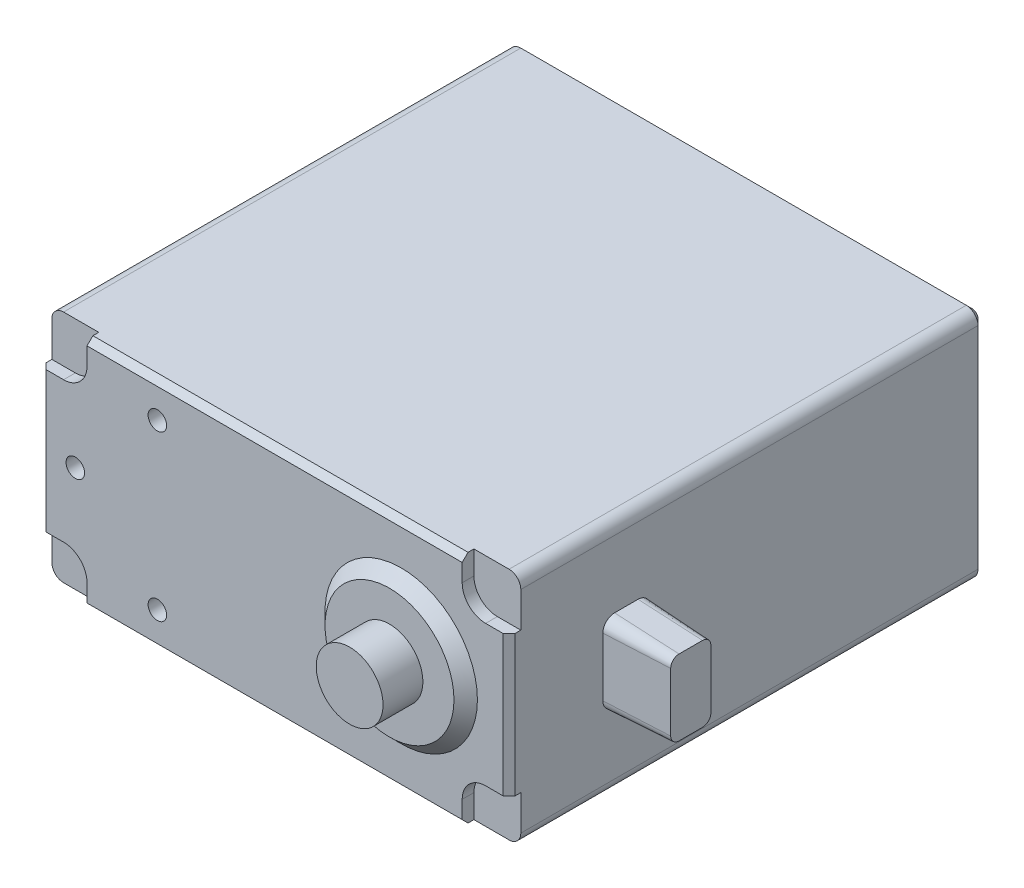
from build123d import *

# Parameters (mm, degrees)
ESQUISSE1_W             = 40
ESQUISSE1_H             = 20
BOSS_EXTRU_1_DEPTH      = 40.5
ESQUISSE2_R             = 0.79
ENL_V_MAT_EXTRU_1_DEPTH = 5
ESQUISSE3_R             = 0.79
ENL_V_MAT_EXTRU_2_DEPTH = 5
ENL_V_MAT_EXTRU_3_DEPTH = 1
CONG_1_R                = 1
ESQUISSE5_R             = 6.5
BOSS_EXTRU_2_DEPTH      = 1
BOSS_EXTRU_2_TAPER      = 45
ESQUISSE6_R             = 2.85
BOSS_EXTRU_3_DEPTH      = 3.4
BOSS_EXTRU_3_DEPTH_BACK = 45.4
ESQUISSE7_R             = 6.5
BOSS_EXTRU_4_DEPTH      = 1
BOSS_EXTRU_4_TAPER      = 45
CHANFREIN1_SIZE         = 0.5
BOSS_EXTRU_5_DEPTH      = 5.5
BOSS_EXTRU_5_TAPER      = 3


with BuildPart() as part:
    # Esquisse1 → Boss.-Extru.1 (new body)
    with BuildSketch(Plane.XY):
        with Locations((4.281789852, 0.18469657)):
            Rectangle(ESQUISSE1_W, ESQUISSE1_H)
    extrude(amount=-BOSS_EXTRU_1_DEPTH)

    # Esquisse2 → Enlèv. mat.-Extru.1 (cut)
    with BuildSketch(Plane.XY):
        with Locations((-12.718210148, 0.18469657)):
            Circle(ESQUISSE2_R)
        with Locations((-5.718210148, 7.18469657)):
            Circle(ESQUISSE2_R)
        with Locations((-5.718210148, -6.81530343)):
            Circle(ESQUISSE2_R)
    extrude(amount=-ENL_V_MAT_EXTRU_1_DEPTH, mode=Mode.SUBTRACT)

    # Esquisse3 → Enlèv. mat.-Extru.2 (cut)
    with BuildSketch(Plane(origin=(0, 0, -40.5), x_dir=(-1, 0, 0), z_dir=(0, 0, -1))):
        with Locations((-1.781789852, 7.68469657)):
            Circle(ESQUISSE3_R)
        with Locations((13.218210148, 7.68469657)):
            Circle(ESQUISSE3_R)
        with Locations((13.218210148, -7.31530343)):
            Circle(ESQUISSE3_R)
        with Locations((-1.781789852, -7.31530343)):
            Circle(ESQUISSE3_R)
    extrude(amount=-ENL_V_MAT_EXTRU_2_DEPTH, mode=Mode.SUBTRACT)

    # Esquisse4 → Enlèv. mat.-Extru.3 (cut)
    with BuildSketch(Plane.XY):
        with BuildLine():
            Line((-15.718210148, 10.18469657), (-11.718210148, 10.18469657))
            Line((-11.718210148, 10.18469657), (-11.718210148, 8.18469657))
            ThreePointArc((-11.718210148, 8.18469657), (-12.303996586, 6.770483008), (-13.718210148, 6.18469657))
            Line((-13.718210148, 6.18469657), (-15.718210148, 6.18469657))
            Line((-15.718210148, 6.18469657), (-15.718210148, 10.18469657))
        make_face()
        with BuildLine():
            Line((-15.718210148, -9.81530343), (-11.718210148, -9.81530343))
            Line((-11.718210148, -9.81530343), (-11.718210148, -7.81530343))
            ThreePointArc((-11.718210148, -7.81530343), (-12.303996586, -6.401089868), (-13.718210148, -5.81530343))
            Line((-13.718210148, -5.81530343), (-15.718210148, -5.81530343))
            Line((-15.718210148, -5.81530343), (-15.718210148, -9.81530343))
        make_face()
        with BuildLine():
            Line((24.281789852, -9.81530343), (20.281789852, -9.81530343))
            Line((20.281789852, -9.81530343), (20.281789852, -7.81530343))
            ThreePointArc((20.281789852, -7.81530343), (20.86757629, -6.401089868), (22.281789852, -5.81530343))
            Line((22.281789852, -5.81530343), (24.281789852, -5.81530343))
            Line((24.281789852, -5.81530343), (24.281789852, -9.81530343))
        make_face()
        with BuildLine():
            Line((24.281789852, 10.18469657), (20.281789852, 10.18469657))
            Line((20.281789852, 10.18469657), (20.281789852, 8.18469657))
            ThreePointArc((20.281789852, 8.18469657), (20.86757629, 6.770483008), (22.281789852, 6.18469657))
            Line((22.281789852, 6.18469657), (24.281789852, 6.18469657))
            Line((24.281789852, 6.18469657), (24.281789852, 10.18469657))
        make_face()
    extrude(amount=-ENL_V_MAT_EXTRU_3_DEPTH, mode=Mode.SUBTRACT)

    # Congé1
    cong_1_edges = [part.edges().sort_by_distance(p)[0] for p in [
        (-15.718210148, 10.18469657, -20.75),
        (24.281789852, 10.18469657, -20.75),
        (24.281789852, -9.81530343, -20.75),
        (-15.718210148, -9.81530343, -20.75),
    ]]
    fillet(cong_1_edges, radius=CONG_1_R)

    # Esquisse5 → Boss.-Extru.2 (add)
    with BuildSketch(Plane.XY):
        with Locations((15.081789852, 0.18469657)):
            Circle(ESQUISSE5_R)
    extrude(amount=BOSS_EXTRU_2_DEPTH, taper=BOSS_EXTRU_2_TAPER)

    # Esquisse6 → Boss.-Extru.3 (add, two sides)
    with BuildSketch(Plane.XY.offset(1)) as boss_extru_3_sk:
        with Locations((15.081789852, 0.18469657)):
            Circle(ESQUISSE6_R)
    extrude(amount=BOSS_EXTRU_3_DEPTH)
    extrude(boss_extru_3_sk.sketch, amount=-BOSS_EXTRU_3_DEPTH_BACK)

    # Esquisse7 → Boss.-Extru.4 (add)
    with BuildSketch(Plane(origin=(0, 0, -40.5), x_dir=(-1, 0, 0), z_dir=(0, 0, -1))):
        with Locations((-15.081789852, 0.18469657)):
            Circle(ESQUISSE7_R)
    extrude(amount=BOSS_EXTRU_4_DEPTH, taper=BOSS_EXTRU_4_TAPER)

    # Chanfrein1
    chanfrein1_edges = [part.edges().sort_by_distance(p)[0] for p in [
        (-15.718210148, 0.18469657, -40.5),
        (4.281789852, -9.81530343, -40.5),
        (4.281789852, 10.18469657, -40.5),
        (24.281789852, 0.18469657, -40.5),
        (-15.425316929, 9.891803351, -40.5),
        (23.988896633, 9.891803351, -40.5),
        (23.988896633, -9.522410211, -40.5),
        (-15.425316929, -9.522410211, -40.5),
        (-15.718210148, 0.18469657, 0),
        (4.281789852, -9.81530343, 0),
        (24.281789852, 0.18469657, 0),
        (4.281789852, 10.18469657, 0),
    ]]
    chamfer(chanfrein1_edges, length=CHANFREIN1_SIZE)

    # Esquisse8 → Boss.-Extru.5 (add)
    with BuildSketch(Plane(origin=(24.281789852, 0, 0), x_dir=(0, 0, -1), z_dir=(1, 0, 0))):
        with BuildLine():
            ThreePointArc((9, 3.463563672), (8.292893219, 3.170670454), (8, 2.463563672))
            Line((8, 2.463563672), (8, -2.536436328))
            ThreePointArc((8, -2.536436328), (8.292893219, -3.243543109), (9, -3.536436328))
            Line((9, -3.536436328), (11, -3.536436328))
            ThreePointArc((11, -3.536436328), (11.707106781, -3.243543109), (12, -2.536436328))
            Line((12, -2.536436328), (12, 2.463563672))
            ThreePointArc((12, 2.463563672), (11.707106781, 3.170670454), (11, 3.463563672))
            Line((11, 3.463563672), (9, 3.463563672))
        make_face()
    extrude(amount=BOSS_EXTRU_5_DEPTH, taper=BOSS_EXTRU_5_TAPER)


solid = part.part
